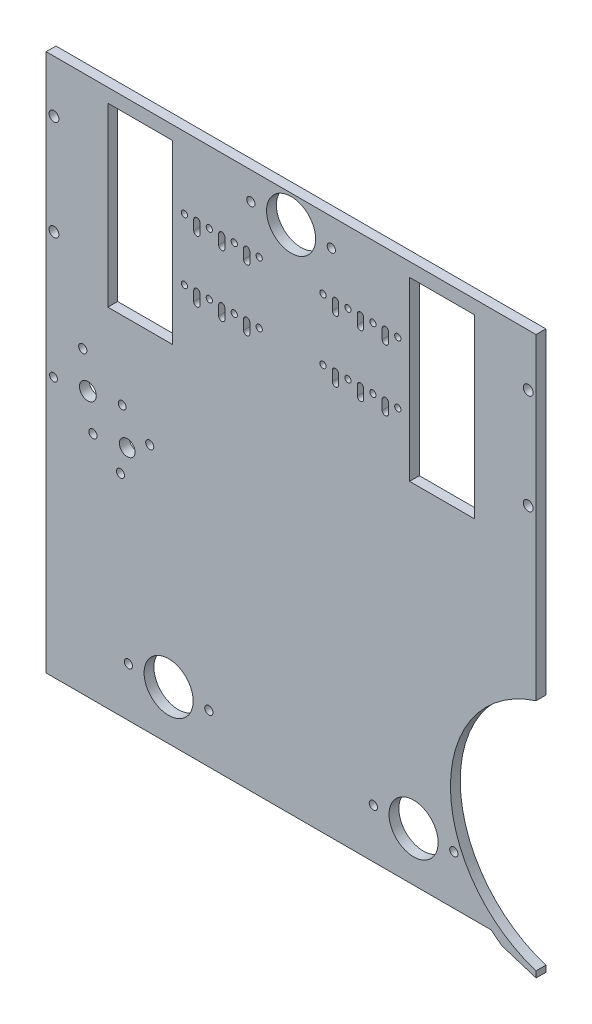
from build123d import *

# Parameters (mm, degrees)
SKETCH1_W               = 249.6
SKETCH1_H               = 340.9
SKETCH1_R               = 2.1
SKETCH1_R_2             = 2.5
SKETCH1_R_3             = 1.59
SKETCH1_R_4             = 12.5
SKETCH1_W_2             = 33
SKETCH1_H_2             = 90
BOSS_EXTRUDE1_DEPTH     = 5
CUT_EXTRUDE3_DEPTH      = 193
CUT_EXTRUDE3_DEPTH_BACK = 193
CUT_EXTRUDE6_DEPTH      = 6
SKETCH8_R               = 2
SKETCH8_R_2             = 2.1
SKETCH8_R_3             = 2.058578644
SKETCH8_R_4             = 4
SKETCH8_R_5             = 4.3
CUT_EXTRUDE7_DEPTH      = 6
SKETCH9_R               = 12.5
SKETCH9_R_2             = 2.1
CUT_EXTRUDE8_DEPTH      = 6


with BuildPart() as part:
    # Sketch1 → Boss-Extrude1 (new body)
    with BuildSketch(Plane.XY):
        with Locations((124.8, -170.45)):
            Rectangle(SKETCH1_W, SKETCH1_H)
        with Locations((104.3, -14)):
            Circle(SKETCH1_R, mode=Mode.SUBTRACT)
        with Locations((245.6, -26.5)):
            Circle(SKETCH1_R_2, mode=Mode.SUBTRACT)
        with Locations((245.6, -77.5)):
            Circle(SKETCH1_R_2, mode=Mode.SUBTRACT)
        with Locations((145.3, -14)):
            Circle(SKETCH1_R, mode=Mode.SUBTRACT)
        with Locations((179.16, -36.375)):
            Circle(SKETCH1_R_3, mode=Mode.SUBTRACT)
        with Locations((179.16, -67.625)):
            Circle(SKETCH1_R_3, mode=Mode.SUBTRACT)
        with Locations((124.8, -14)):
            Circle(SKETCH1_R_4, mode=Mode.SUBTRACT)
        with Locations((141.06, -36.375)):
            Circle(SKETCH1_R_3, mode=Mode.SUBTRACT)
        with Locations((153.76, -36.375)):
            Circle(SKETCH1_R_3, mode=Mode.SUBTRACT)
        with Locations((166.46, -36.375)):
            Circle(SKETCH1_R_3, mode=Mode.SUBTRACT)
        with Locations((141.06, -67.625)):
            Circle(SKETCH1_R_3, mode=Mode.SUBTRACT)
        with Locations((153.76, -67.625)):
            Circle(SKETCH1_R_3, mode=Mode.SUBTRACT)
        with Locations((166.46, -67.625)):
            Circle(SKETCH1_R_3, mode=Mode.SUBTRACT)
        with Locations((83.14, -67.625)):
            Circle(SKETCH1_R_3, mode=Mode.SUBTRACT)
        with Locations((95.84, -67.625)):
            Circle(SKETCH1_R_3, mode=Mode.SUBTRACT)
        with Locations((108.54, -67.625)):
            Circle(SKETCH1_R_3, mode=Mode.SUBTRACT)
        with Locations((83.14, -36.375)):
            Circle(SKETCH1_R_3, mode=Mode.SUBTRACT)
        with Locations((95.84, -36.375)):
            Circle(SKETCH1_R_3, mode=Mode.SUBTRACT)
        with Locations((108.54, -36.375)):
            Circle(SKETCH1_R_3, mode=Mode.SUBTRACT)
        with Locations((70.44, -67.625)):
            Circle(SKETCH1_R_3, mode=Mode.SUBTRACT)
        with Locations((70.44, -36.375)):
            Circle(SKETCH1_R_3, mode=Mode.SUBTRACT)
        with Locations((4, -77.5)):
            Circle(SKETCH1_R_2, mode=Mode.SUBTRACT)
        with Locations((4, -26.5)):
            Circle(SKETCH1_R_2, mode=Mode.SUBTRACT)
        with Locations((201.66, -52)):
            Rectangle(SKETCH1_W_2, SKETCH1_H_2, mode=Mode.SUBTRACT)
        with BuildLine():
            Line((145.8225, -36.375), (145.8225, -41.375))
            ThreePointArc((145.8225, -41.375), (147.41, -42.9625), (148.9975, -41.375))
            Line((148.9975, -41.375), (148.9975, -36.375))
            ThreePointArc((148.9975, -36.375), (147.41, -34.7875), (145.8225, -36.375))
        make_face(mode=Mode.SUBTRACT)
        with BuildLine():
            Line((158.52, -36.375), (158.52, -41.375))
            ThreePointArc((158.52, -41.375), (160.11, -42.965), (161.7, -41.375))
            Line((161.7, -41.375), (161.7, -36.375))
            ThreePointArc((161.7, -36.375), (160.11, -34.785), (158.52, -36.375))
        make_face(mode=Mode.SUBTRACT)
        with BuildLine():
            Line((171.22, -36.375), (171.22, -41.375))
            ThreePointArc((171.22, -41.375), (172.81, -42.965), (174.4, -41.375))
            Line((174.4, -41.375), (174.4, -36.375))
            ThreePointArc((174.4, -36.375), (172.81, -34.785), (171.22, -36.375))
        make_face(mode=Mode.SUBTRACT)
        with BuildLine():
            Line((145.8225, -67.625), (145.8225, -72.625))
            ThreePointArc((145.8225, -72.625), (147.41, -74.2125), (148.9975, -72.625))
            Line((148.9975, -72.625), (148.9975, -67.625))
            ThreePointArc((148.9975, -67.625), (147.41, -66.0375), (145.8225, -67.625))
        make_face(mode=Mode.SUBTRACT)
        with BuildLine():
            Line((158.52, -67.625), (158.52, -72.625))
            ThreePointArc((158.52, -72.625), (160.11, -74.215), (161.7, -72.625))
            Line((161.7, -72.625), (161.7, -67.625))
            ThreePointArc((161.7, -67.625), (160.11, -66.035), (158.52, -67.625))
        make_face(mode=Mode.SUBTRACT)
        with BuildLine():
            Line((171.22, -67.625), (171.22, -72.625))
            ThreePointArc((171.22, -72.625), (172.81, -74.215), (174.4, -72.625))
            Line((174.4, -72.625), (174.4, -67.625))
            ThreePointArc((174.4, -67.625), (172.81, -66.035), (171.22, -67.625))
        make_face(mode=Mode.SUBTRACT)
        with BuildLine():
            Line((103.7775, -36.375), (103.7775, -41.375))
            ThreePointArc((103.7775, -41.375), (102.19, -42.9625), (100.6025, -41.375))
            Line((100.6025, -41.375), (100.6025, -36.375))
            ThreePointArc((100.6025, -36.375), (102.19, -34.7875), (103.7775, -36.375))
        make_face(mode=Mode.SUBTRACT)
        with BuildLine():
            Line((91.08, -36.375), (91.08, -41.375))
            ThreePointArc((91.08, -41.375), (89.49, -42.965), (87.9, -41.375))
            Line((87.9, -41.375), (87.9, -36.375))
            ThreePointArc((87.9, -36.375), (89.49, -34.785), (91.08, -36.375))
        make_face(mode=Mode.SUBTRACT)
        with BuildLine():
            Line((78.38, -36.375), (78.38, -41.375))
            ThreePointArc((78.38, -41.375), (76.79, -42.965), (75.2, -41.375))
            Line((75.2, -41.375), (75.2, -36.375))
            ThreePointArc((75.2, -36.375), (76.79, -34.785), (78.38, -36.375))
        make_face(mode=Mode.SUBTRACT)
        with BuildLine():
            Line((103.7775, -67.625), (103.7775, -72.625))
            ThreePointArc((103.7775, -72.625), (102.19, -74.2125), (100.6025, -72.625))
            Line((100.6025, -72.625), (100.6025, -67.625))
            ThreePointArc((100.6025, -67.625), (102.19, -66.0375), (103.7775, -67.625))
        make_face(mode=Mode.SUBTRACT)
        with BuildLine():
            Line((91.08, -67.625), (91.08, -72.625))
            ThreePointArc((91.08, -72.625), (89.49, -74.215), (87.9, -72.625))
            Line((87.9, -72.625), (87.9, -67.625))
            ThreePointArc((87.9, -67.625), (89.49, -66.035), (91.08, -67.625))
        make_face(mode=Mode.SUBTRACT)
        with BuildLine():
            Line((78.38, -67.625), (78.38, -72.625))
            ThreePointArc((78.38, -72.625), (76.79, -74.215), (75.2, -72.625))
            Line((75.2, -72.625), (75.2, -67.625))
            ThreePointArc((75.2, -67.625), (76.79, -66.035), (78.38, -67.625))
        make_face(mode=Mode.SUBTRACT)
        with Locations((47.94, -52)):
            Rectangle(SKETCH1_W_2, SKETCH1_H_2, mode=Mode.SUBTRACT)
    extrude(amount=BOSS_EXTRUDE1_DEPTH)

    # Sketch4 → Cut-Extrude3 (cut, two sides)
    with BuildSketch(Plane.XY.offset(5)) as cut_extrude3_sk:
        with BuildLine():
            Line((249.6, -161.594545719), (249.6, -280.754609783))
            ThreePointArc((249.6, -280.754609783), (205.980407386, -221.174577751), (249.6, -161.594545719))
        make_face()
    extrude(amount=CUT_EXTRUDE3_DEPTH, mode=Mode.SUBTRACT)
    extrude(cut_extrude3_sk.sketch, amount=-CUT_EXTRUDE3_DEPTH_BACK, mode=Mode.SUBTRACT)

    # Sketch7 → Cut-Extrude6 (cut, through all)
    with BuildSketch(Plane.XY.offset(5)):
        Polygon((249.6, -283.901637295), (232.162192493, -278.37574383), (226.608591706, -274.129323659), (0, -274.129323659), (0, -340.9), (249.6, -340.9), align=None)
    extrude(amount=-CUT_EXTRUDE6_DEPTH, mode=Mode.SUBTRACT)

    # Sketch8 → Cut-Extrude7 (cut, through all)
    with BuildSketch(Plane.XY.offset(5)):
        with Locations((3.765, -141.718358436)):
            Circle(SKETCH8_R)
        with Locations((18.683520247, -121.657507167)):
            Circle(SKETCH8_R_2)
        with Locations((23.825851269, -156.636878683)):
            Circle(SKETCH8_R_2)
        with Locations((37.868447157, -167.079842856)):
            Circle(SKETCH8_R_3)
        with Locations((41.315537027, -154.065713172)):
            Circle(SKETCH8_R_4)
        with Locations((38.744371516, -136.576027414)):
            Circle(SKETCH8_R)
        with Locations((21.254685758, -139.147192925)):
            Circle(SKETCH8_R_5)
        with Locations((52.786967404, -147.018991586)):
            Circle(SKETCH8_R_3)
    extrude(amount=-CUT_EXTRUDE7_DEPTH, mode=Mode.SUBTRACT)

    # Sketch9 → Cut-Extrude8 (cut, through all)
    with BuildSketch(Plane.XY.offset(5)):
        with Locations((62.4, -249.129323659)):
            Circle(SKETCH9_R)
        with Locations((82.9, -249.129323659)):
            Circle(SKETCH9_R_2)
        with Locations((41.9, -249.129323659)):
            Circle(SKETCH9_R_2)
        with Locations((207.7, -249.129323659)):
            Circle(SKETCH9_R_2)
        with Locations((166.7, -249.129323659)):
            Circle(SKETCH9_R_2)
        with Locations((187.2, -249.129323659)):
            Circle(SKETCH9_R)
    extrude(amount=-CUT_EXTRUDE8_DEPTH, mode=Mode.SUBTRACT)


solid = part.part
